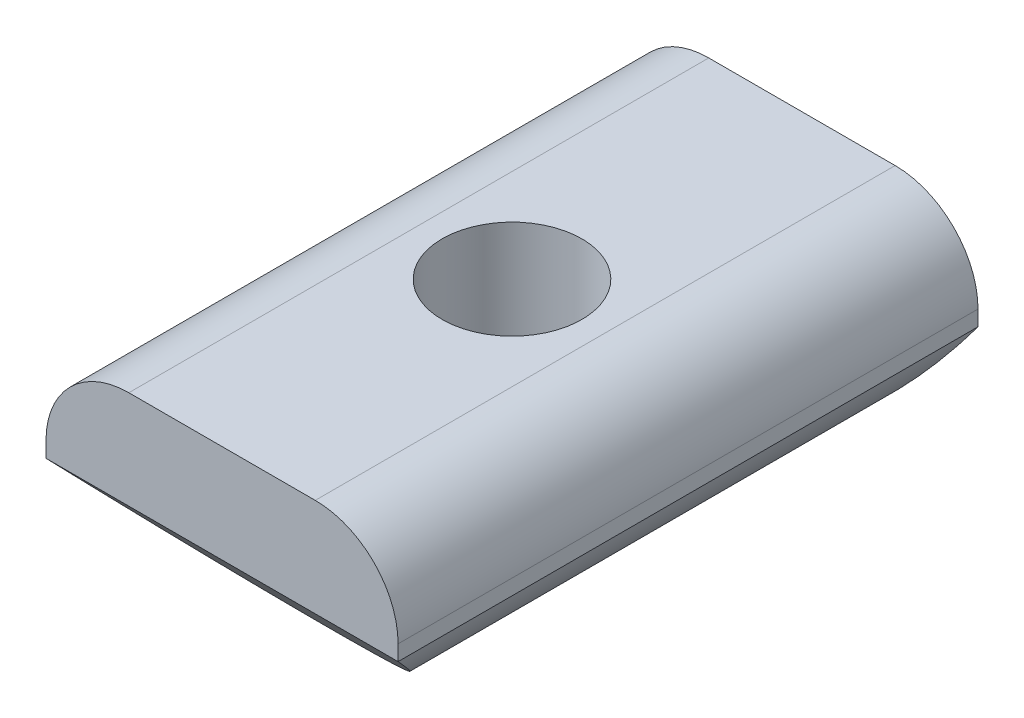
from build123d import *

# Parameters (mm, degrees)
EXTRUSION1_DEPTH             = 14
ESQUISSE2_R                  = 3.375
ENL_V_MAT_EXTRU_1_DEPTH      = 11
ENL_V_MAT_EXTRU_2_DEPTH      = 9.5000001
ENL_V_MAT_EXTRU_2_DEPTH_BACK = 9.5000001


with BuildPart() as part:
    # Esquisse1 → Extrusion1 (new body, symmetric)
    with BuildSketch(Plane.XY):
        with BuildLine():
            Line((-8.5, -4.242640687), (-8.5, -3.5))
            ThreePointArc((-8.5, -3.5), (-7.328427125, -0.671572875), (-4.5, 0.5))
            Line((-4.5, 0.5), (4.5, 0.5))
            ThreePointArc((4.5, 0.5), (7.328427125, -0.671572875), (8.5, -3.5))
            Line((8.5, -3.5), (8.5, -4.242640687))
            ThreePointArc((8.5, -4.242640687), (0, -9.5), (-8.5, -4.242640687))
        make_face()
    extrude(amount=EXTRUSION1_DEPTH, both=True)

    # Esquisse2 → Enlèv. mat.-Extru.1 (cut, through all)
    with BuildSketch(Plane(origin=(0, 0.5, 0), x_dir=(-1, 0, 0), z_dir=(0, 1, 0))):
        Circle(ESQUISSE2_R)
    extrude(amount=-ENL_V_MAT_EXTRU_1_DEPTH, mode=Mode.SUBTRACT)

    # Esquisse3 → Enlèv. mat.-Extru.2 (cut, two sides)
    with BuildSketch(Plane(origin=(0, 0, 0), x_dir=(0, 0, -1), z_dir=(1, 0, 0))) as enl_v_mat_extru_2_sk:
        Polygon((14, -9.5), (14, -4.242640687), (9, -9.5), align=None)
        Polygon((-14, -9.5), (-14, -4.242640687), (-9, -9.5), align=None)
    extrude(amount=ENL_V_MAT_EXTRU_2_DEPTH, mode=Mode.SUBTRACT)
    extrude(enl_v_mat_extru_2_sk.sketch, amount=-ENL_V_MAT_EXTRU_2_DEPTH_BACK, mode=Mode.SUBTRACT)


solid = part.part
